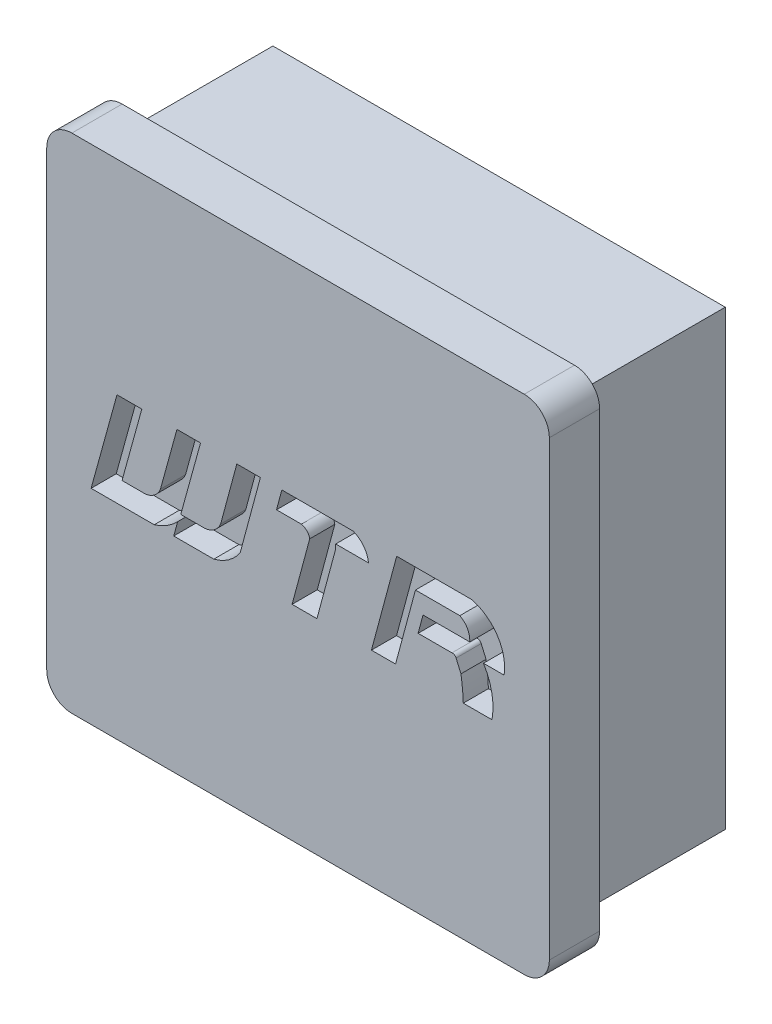
from build123d import *

# Parameters (mm, degrees)
SKETCH_1_W          = 18
SKETCH_1_H          = 18
EXTRUDE_1_DEPTH     = 6
SKETCH_3_W          = 20
SKETCH_3_H          = 20
EXTRUDE_2_DEPTH     = 2
FILLET_1_R          = 1
CUT_EXTRUDE_2_DEPTH = 1


with BuildPart() as part:
    # 草图1 → 凸台-拉伸1 (new body)
    with BuildSketch(Plane.XY):
        Rectangle(SKETCH_1_W, SKETCH_1_H)
    extrude(amount=EXTRUDE_1_DEPTH)

    # 草图3 → 凸台-拉伸2 (add)
    with BuildSketch(Plane.XY.offset(6)):
        Rectangle(SKETCH_3_W, SKETCH_3_H)
    extrude(amount=EXTRUDE_2_DEPTH)

    # 圆角1
    fillet_1_edges = [part.edges().sort_by_distance(p)[0] for p in [
        (10, -10, 7),
        (10, 10, 7),
        (-10, 10, 7),
        (-10, -10, 7),
    ]]
    fillet(fillet_1_edges, radius=FILLET_1_R)

    # 草图5 → 切除-拉伸2 (cut)
    with BuildSketch(Plane.XY.offset(8)):
        with BuildLine():
            Line((-7.204561004, 1.879394949), (-8.234522443, -1.859506165))
            Line((-8.234522443, -1.859506165), (-5.723109619, -1.859506165))
            ThreePointArc((-5.723109619, -1.859506165), (-5.218538697, -1.632457047), (-4.78861912, -1.284157931))
            Line((-4.78861912, -1.284157931), (-4.947111275, -1.859506165))
            Line((-4.947111275, -1.859506165), (-3.352787404, -1.859506165))
            ThreePointArc((-3.352787404, -1.859506165), (-2.759972983, -1.585355224), (-2.30360072, -1.118116491))
            Line((-2.30360072, -1.118116491), (-1.497804292, 1.879394949))
            Line((-1.497804292, 1.879394949), (-2.436323584, 1.879394949))
            Line((-2.436323584, 1.879394949), (-3.079504637, -0.513197642))
            ThreePointArc((-3.079504637, -0.513197642), (-3.32542599, -0.827982147), (-3.696433402, -0.976036515))
            Line((-3.696433402, -0.976036515), (-4.666789972, -0.976036515))
            Line((-4.666789972, -0.976036515), (-3.880199418, 1.879394949))
            Line((-3.880199418, 1.879394949), (-4.81871871, 1.879394949))
            Line((-4.81871871, 1.879394949), (-5.477810253, -0.513197642))
            ThreePointArc((-5.477810253, -0.513197642), (-5.7047457, -0.820725721), (-6.053961641, -0.976036515))
            Line((-6.053961641, -0.976036515), (-7.003517302, -0.976036515))
            Line((-7.003517302, -0.976036515), (-6.216926747, 1.879394949))
            Line((-6.216926747, 1.879394949), (-7.204561004, 1.879394949))
        make_face()
        with BuildLine():
            Line((-0.857127264, 1.088853082), (-0.644612375, 1.879394949))
            Line((-0.644612375, 1.879394949), (2.196209614, 1.879394949))
            ThreePointArc((2.196209614, 1.879394949), (2.612575491, 1.570775142), (2.803252851, 1.088853082))
            Line((2.803252851, 1.088853082), (1.498562909, 1.088853082))
            Line((1.498562909, 1.088853082), (1.498562909, 0.920146657))
            Line((1.498562909, 0.920146657), (0.751331627, -1.859506165))
            Line((0.751331627, -1.859506165), (-0.236975463, -1.859506165))
            Line((-0.236975463, -1.859506165), (0.463990432, 0.748042361))
            ThreePointArc((0.463990432, 0.748042361), (0.35056842, 0.970657535), (0.130450539, 1.088853082))
            Line((0.130450539, 1.088853082), (-0.857127264, 1.088853082))
        make_face()
        with BuildLine():
            Line((3.92496477, 1.879394949), (2.919866632, -1.859506165))
            Line((2.919866632, -1.859506165), (3.879786702, -1.859506165))
            Line((3.879786702, -1.859506165), (4.67236995, 1.088853082))
            Line((4.67236995, 1.088853082), (6.439189541, 1.088853082))
            ThreePointArc((6.439189541, 1.088853082), (6.74191311, 0.79302609), (6.831437365, 0.379334689))
            Line((6.831437365, 0.379334689), (4.973337874, 0.379334689))
            Line((4.973337874, 0.379334689), (4.777076341, -0.350745725))
            Line((4.777076341, -0.350745725), (6.123295998, -0.350745725))
            ThreePointArc((6.123295998, -0.350745725), (6.221884558, -0.372626448), (6.288711068, -0.448340962))
            Line((6.288711068, -0.448340962), (6.481965147, -0.894824524))
            ThreePointArc((6.481965147, -0.894824524), (6.543334906, -1.375731382), (6.574951556, -1.859506165))
            Line((6.574951556, -1.859506165), (7.717356009, -1.859506165))
            ThreePointArc((7.717356009, -1.859506165), (7.71253802, -0.938991532), (7.378394237, -0.081251283))
            Line((7.378394237, -0.081251283), (8.199786702, -0.081251283))
            ThreePointArc((8.199786702, -0.081251283), (7.934816182, 1.144935193), (6.917805112, 1.879394949))
            Line((6.917805112, 1.879394949), (3.92496477, 1.879394949))
        make_face()
    extrude(amount=-CUT_EXTRUDE_2_DEPTH, mode=Mode.SUBTRACT)


solid = part.part
